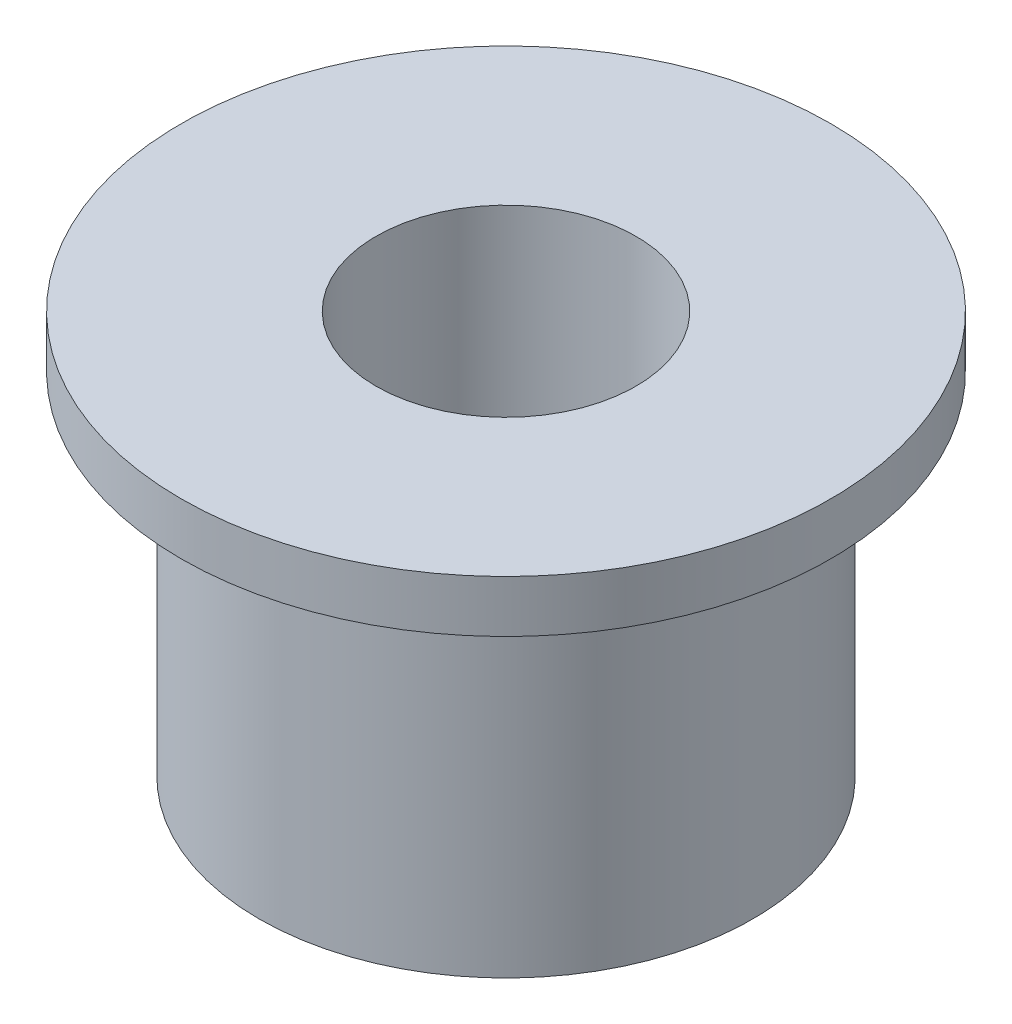
from build123d import *

# Parameters (mm, degrees)
SKETCH2_R           = 25
SKETCH2_R_2         = 19
BOSS_EXTRUDE1_DEPTH = 4
SKETCH2_3_R         = 19
SKETCH2_3_R_2       = 10
BOSS_EXTRUDE2_DEPTH = 31


with BuildPart() as part:
    # Sketch2 → Boss-Extrude1 (new body)
    with BuildSketch(Plane(origin=(0, 0, 0), x_dir=(1, 0, 0), z_dir=(0, 1, 0))):
        Circle(SKETCH2_R)
        Circle(SKETCH2_R_2, mode=Mode.SUBTRACT)
    extrude(amount=-BOSS_EXTRUDE1_DEPTH)

    # Sketch2_3 → Boss-Extrude2 (add)
    with BuildSketch(Plane(origin=(0, 0, 0), x_dir=(1, 0, 0), z_dir=(0, 1, 0))):
        Circle(SKETCH2_3_R)
        Circle(SKETCH2_3_R_2, mode=Mode.SUBTRACT)
    extrude(amount=-BOSS_EXTRUDE2_DEPTH)


solid = part.part
